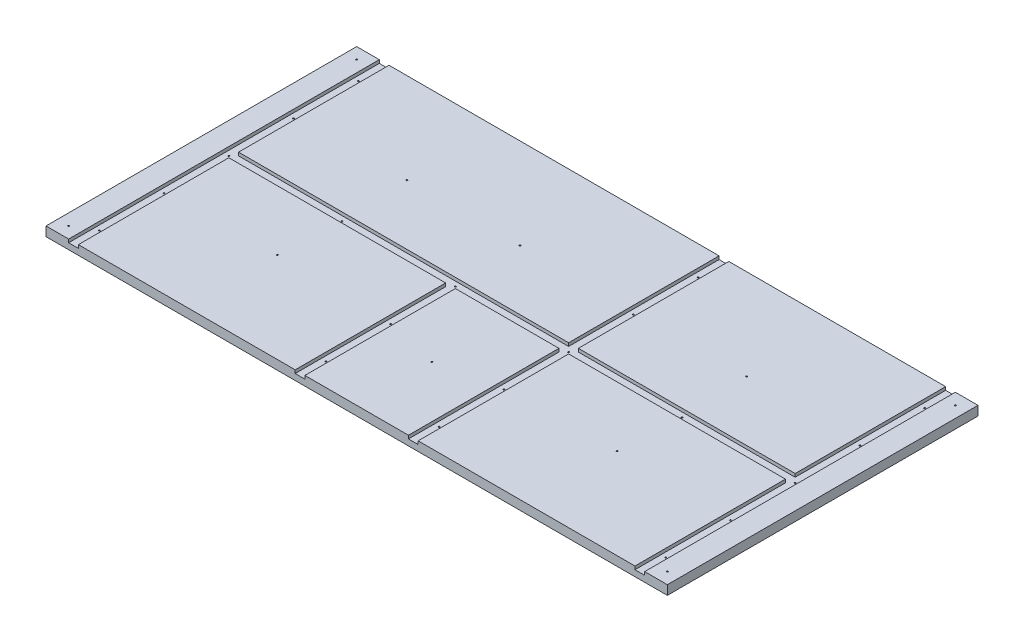
from build123d import *

# Parameters (mm, degrees)
SKETCH1_W               = 1219.2
SKETCH1_H               = 609.6
BOSS_EXTRUDE1_DEPTH     = 18.25625
CUT_EXTRUDE1_DEPTH      = 6.35
SKETCH4_R               = 1.397
CUT_EXTRUDE2_DEPTH      = 7.35
CUT_EXTRUDE2_DEPTH_BACK = 12.90625


with BuildPart() as part:
    # Sketch1 → Boss-Extrude1 (new body)
    with BuildSketch(Plane(origin=(0, 0, 0), x_dir=(1, 0, 0), z_dir=(0, 1, 0))):
        Rectangle(SKETCH1_W, SKETCH1_H)
    extrude(amount=BOSS_EXTRUDE1_DEPTH)

    # Sketch2 → Cut-Extrude1 (cut)
    with BuildSketch(Plane(origin=(0, 18.25625, 0), x_dir=(1, 0, 0), z_dir=(0, 1, 0))):
        Polygon((-565.15, 304.8), (-546.1, 304.8), (-546.1, 9.525), (101.6, 9.525), (101.6, 304.8), (120.65, 304.8), (120.65, 9.525), (546.1, 9.525), (546.1, 304.8), (565.15, 304.8), (565.15, -304.8), (546.1, -304.8), (546.1, -9.525), (120.65, -9.525), (120.65, -304.8), (101.6, -304.8), (101.6, -9.525), (-101.6, -9.525), (-101.6, -304.8), (-120.65, -304.8), (-120.65, -9.525), (-546.1, -9.525), (-546.1, -304.8), (-565.15, -304.8), align=None)
    extrude(amount=-CUT_EXTRUDE1_DEPTH, mode=Mode.SUBTRACT)

    # Sketch4 → Cut-Extrude2 (cut, two sides)
    with BuildSketch(Plane(origin=(0, 11.90625, 0), x_dir=(1, 0, 0), z_dir=(0, 1, 0))) as cut_extrude2_sk:
        with Locations((-555.625, 254)):
            Circle(SKETCH4_R)
        with Locations((111.125, 254)):
            Circle(SKETCH4_R)
        with Locations((555.625, 254)):
            Circle(SKETCH4_R)
        with Locations((-333.375, 127)):
            Circle(SKETCH4_R)
        with Locations((-111.125, 127)):
            Circle(SKETCH4_R)
        with Locations((111.125, 127)):
            Circle(SKETCH4_R)
        with Locations((333.375, 127)):
            Circle(SKETCH4_R)
        with Locations((555.625, 127)):
            Circle(SKETCH4_R)
        with Locations((-333.375, 0)):
            Circle(SKETCH4_R)
        with Locations((-111.125, 0)):
            Circle(SKETCH4_R)
        with Locations((111.125, 0)):
            Circle(SKETCH4_R)
        with Locations((333.375, 0)):
            Circle(SKETCH4_R)
        with Locations((555.625, 0)):
            Circle(SKETCH4_R)
        with Locations((-333.375, -127)):
            Circle(SKETCH4_R)
        with Locations((-111.125, -127)):
            Circle(SKETCH4_R)
        with Locations((111.125, -127)):
            Circle(SKETCH4_R)
        with Locations((333.375, -127)):
            Circle(SKETCH4_R)
        with Locations((555.625, -127)):
            Circle(SKETCH4_R)
        with Locations((-111.125, -254)):
            Circle(SKETCH4_R)
        with Locations((111.125, -254)):
            Circle(SKETCH4_R)
        with Locations((555.625, -254)):
            Circle(SKETCH4_R)
        with Locations((-555.625, 127)):
            Circle(SKETCH4_R)
        with Locations((-555.625, 0)):
            Circle(SKETCH4_R)
        with Locations((-555.625, -127)):
            Circle(SKETCH4_R)
        with Locations((-555.625, -254)):
            Circle(SKETCH4_R)
        with Locations((-587.375, 282.575)):
            Circle(SKETCH4_R)
        with Locations((587.375, 282.575)):
            Circle(SKETCH4_R)
        with Locations((587.375, -282.575)):
            Circle(SKETCH4_R)
        with Locations((-587.375, -282.575)):
            Circle(SKETCH4_R)
        with Locations((0, -157.1625)):
            Circle(SKETCH4_R)
    extrude(amount=CUT_EXTRUDE2_DEPTH, mode=Mode.SUBTRACT)
    extrude(cut_extrude2_sk.sketch, amount=-CUT_EXTRUDE2_DEPTH_BACK, mode=Mode.SUBTRACT)


solid = part.part
